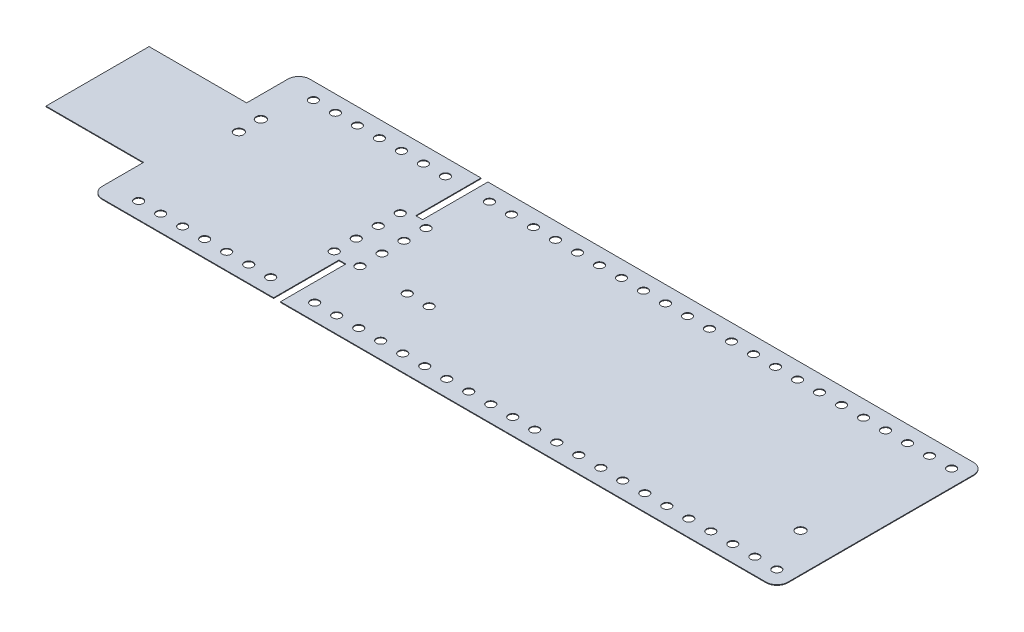
from build123d import *

# Parameters (mm, degrees)
BOSS_EXTRUDE1_DEPTH = 0.03935
SKETCH2_R           = 0.5
CUT_EXTRUDE1_DEPTH  = 1.0787
SKETCH3_R           = 0.5
CUT_EXTRUDE2_DEPTH  = 1.0787
SKETCH4_R           = 0.5
CUT_EXTRUDE3_DEPTH  = 1.0787
SKETCH5_W           = 0.8
SKETCH5_H           = 7.6
CUT_EXTRUDE4_DEPTH  = 1.0787
SKETCH6_R           = 0.5461
CUT_EXTRUDE5_DEPTH  = 1.0787
SKETCH7_R           = 0.5461
CUT_EXTRUDE6_DEPTH  = 1.0787
FILLET1_R           = 1.27


with BuildPart() as part:
    # Sketch1 → Boss-Extrude1 (new body, symmetric)
    with BuildSketch(Plane(origin=(0, 0, 0), x_dir=(1, 0, 0), z_dir=(0, 1, 0))):
        Polygon((91.11, -12.065), (11.35, -12.065), (11.35, -5.995), (0, -5.995), (0, 5.995), (11.35, 5.995), (11.35, 12.065), (91.11, 12.065), align=None)
    extrude(amount=BOSS_EXTRUDE1_DEPTH, both=True)

    # Sketch2 → Cut-Extrude1 (cut, through all)
    with BuildSketch(Plane(origin=(0, 0.03935, 0), x_dir=(1, 0, 0), z_dir=(0, 1, 0))):
        with Locations((14.95, 10.165)):
            Circle(SKETCH2_R)
        with Locations((17.51, 10.165)):
            Circle(SKETCH2_R)
        with Locations((20.07, 10.165)):
            Circle(SKETCH2_R)
        with Locations((22.63, 10.165)):
            Circle(SKETCH2_R)
        with Locations((25.19, 10.165)):
            Circle(SKETCH2_R)
        with Locations((27.75, 10.165)):
            Circle(SKETCH2_R)
        with Locations((30.31, 10.165)):
            Circle(SKETCH2_R)
        with Locations((35.43, 10.165)):
            Circle(SKETCH2_R)
        with Locations((37.99, 10.165)):
            Circle(SKETCH2_R)
        with Locations((40.55, 10.165)):
            Circle(SKETCH2_R)
        with Locations((43.11, 10.165)):
            Circle(SKETCH2_R)
        with Locations((45.67, 10.165)):
            Circle(SKETCH2_R)
        with Locations((48.23, 10.165)):
            Circle(SKETCH2_R)
        with Locations((50.79, 10.165)):
            Circle(SKETCH2_R)
        with Locations((53.35, 10.165)):
            Circle(SKETCH2_R)
        with Locations((55.91, 10.165)):
            Circle(SKETCH2_R)
        with Locations((58.47, 10.165)):
            Circle(SKETCH2_R)
        with Locations((61.03, 10.165)):
            Circle(SKETCH2_R)
        with Locations((63.59, 10.165)):
            Circle(SKETCH2_R)
        with Locations((66.15, 10.165)):
            Circle(SKETCH2_R)
        with Locations((68.71, 10.165)):
            Circle(SKETCH2_R)
        with Locations((71.27, 10.165)):
            Circle(SKETCH2_R)
        with Locations((73.83, 10.165)):
            Circle(SKETCH2_R)
        with Locations((76.39, 10.165)):
            Circle(SKETCH2_R)
        with Locations((78.95, 10.165)):
            Circle(SKETCH2_R)
        with Locations((81.51, 10.165)):
            Circle(SKETCH2_R)
        with Locations((84.07, 10.165)):
            Circle(SKETCH2_R)
        with Locations((86.63, 10.165)):
            Circle(SKETCH2_R)
        with Locations((89.19, 10.165)):
            Circle(SKETCH2_R)
    cut_extrude1 = extrude(amount=-CUT_EXTRUDE1_DEPTH, mode=Mode.SUBTRACT)

    # Mirror1: Cut-Extrude1 across plane
    add(cut_extrude1.mirror(Plane.XY), mode=Mode.SUBTRACT)

    # Sketch3 → Cut-Extrude2 (cut, through all)
    with BuildSketch(Plane(origin=(0, 0.03935, 0), x_dir=(1, 0, 0), z_dir=(0, 1, 0))):
        with Locations((31.396543447, 3.82006498)):
            Circle(SKETCH3_R)
        with Locations((34.396543447, 3.82006498)):
            Circle(SKETCH3_R)
        with Locations((34.396543447, 1.26006498)):
            Circle(SKETCH3_R)
        with Locations((34.396543447, -1.29993502)):
            Circle(SKETCH3_R)
        with Locations((34.396543447, -3.85993502)):
            Circle(SKETCH3_R)
        with Locations((31.396543447, 1.26006498)):
            Circle(SKETCH3_R)
        with Locations((31.396543447, -1.29993502)):
            Circle(SKETCH3_R)
        with Locations((31.396543447, -3.85993502)):
            Circle(SKETCH3_R)
    extrude(amount=-CUT_EXTRUDE2_DEPTH, mode=Mode.SUBTRACT)

    # Sketch4 → Cut-Extrude3 (cut, through all)
    with BuildSketch(Plane(origin=(0, 0.03935, 0), x_dir=(1, 0, 0), z_dir=(0, 1, 0))):
        with Locations((39.896471903, -3.871334333)):
            Circle(SKETCH4_R)
        with Locations((42.456471903, -3.871334333)):
            Circle(SKETCH4_R)
    extrude(amount=-CUT_EXTRUDE3_DEPTH, mode=Mode.SUBTRACT)

    # Sketch5 → Cut-Extrude4 (cut, through all)
    with BuildSketch(Plane(origin=(0, 0.03935, 0), x_dir=(1, 0, 0), z_dir=(0, 1, 0))):
        with Locations((32.95, 8.265)):
            Rectangle(SKETCH5_W, SKETCH5_H)
    cut_extrude4 = extrude(amount=-CUT_EXTRUDE4_DEPTH, mode=Mode.SUBTRACT)

    # Mirror2: Cut-Extrude4 across plane
    add(cut_extrude4.mirror(Plane.XY), mode=Mode.SUBTRACT)

    # Sketch6 → Cut-Extrude5 (cut, through all)
    with BuildSketch(Plane(origin=(0, 0.03935, 0), x_dir=(1, 0, 0), z_dir=(0, 1, 0))):
        with Locations((13.827489542, 5.174256262)):
            Circle(SKETCH6_R)
        with Locations((13.827489542, 2.614256262)):
            Circle(SKETCH6_R)
    extrude(amount=-CUT_EXTRUDE5_DEPTH, mode=Mode.SUBTRACT)

    # Sketch7 → Cut-Extrude6 (cut, through all)
    with BuildSketch(Plane(origin=(0, 0.03935, 0), x_dir=(1, 0, 0), z_dir=(0, 1, 0))):
        with Locations((86.654615346, -4.866346519)):
            Circle(SKETCH7_R)
    extrude(amount=-CUT_EXTRUDE6_DEPTH, mode=Mode.SUBTRACT)

    # Fillet1
    fillet1_edges = [part.edges().sort_by_distance(p)[0] for p in [
        (11.35, 0, -12.065),
        (91.11, 0, -12.065),
        (91.11, 0, 12.065),
        (11.35, 0, 12.065),
    ]]
    fillet(fillet1_edges, radius=FILLET1_R)


solid = part.part
